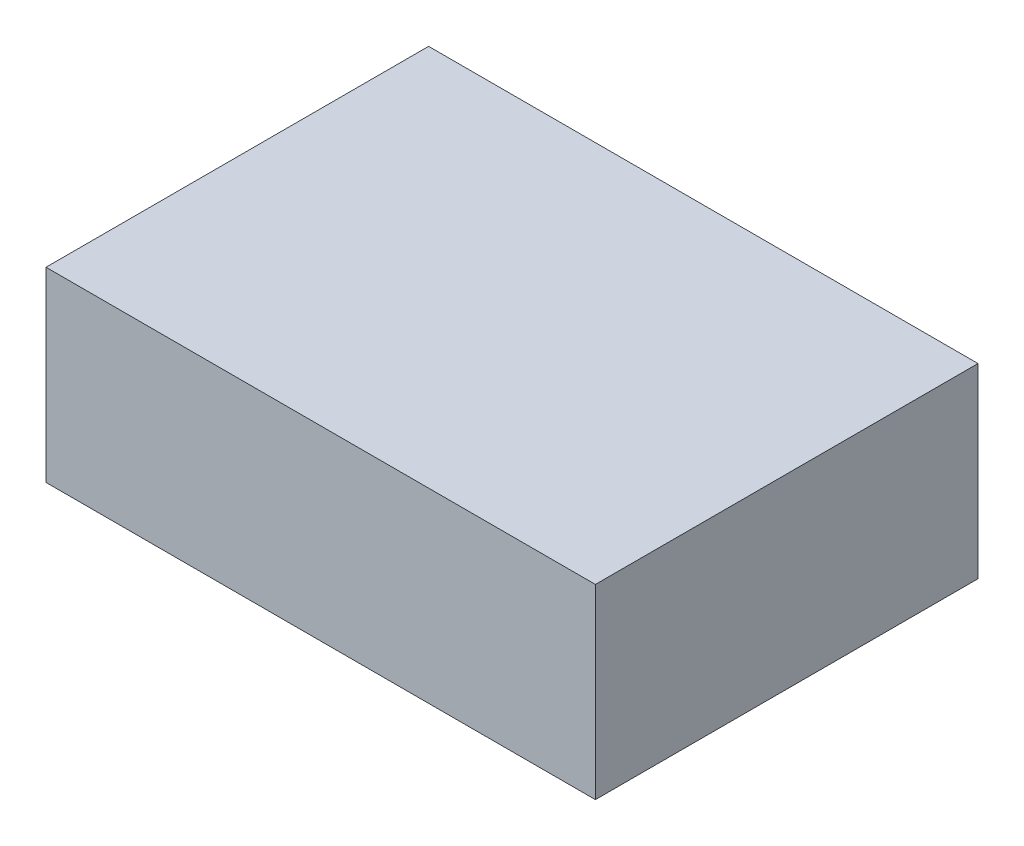
from build123d import *

# Parameters (mm, degrees)
SKETCH1_W           = 112
SKETCH1_H           = 78
BOSS_EXTRUDE1_DEPTH = 38


with BuildPart() as part:
    # Sketch1 → Boss-Extrude1 (new body)
    with BuildSketch(Plane(origin=(0, 0, 0), x_dir=(1, 0, 0), z_dir=(0, 1, 0))):
        Rectangle(SKETCH1_W, SKETCH1_H)
    extrude(amount=BOSS_EXTRUDE1_DEPTH)


solid = part.part
